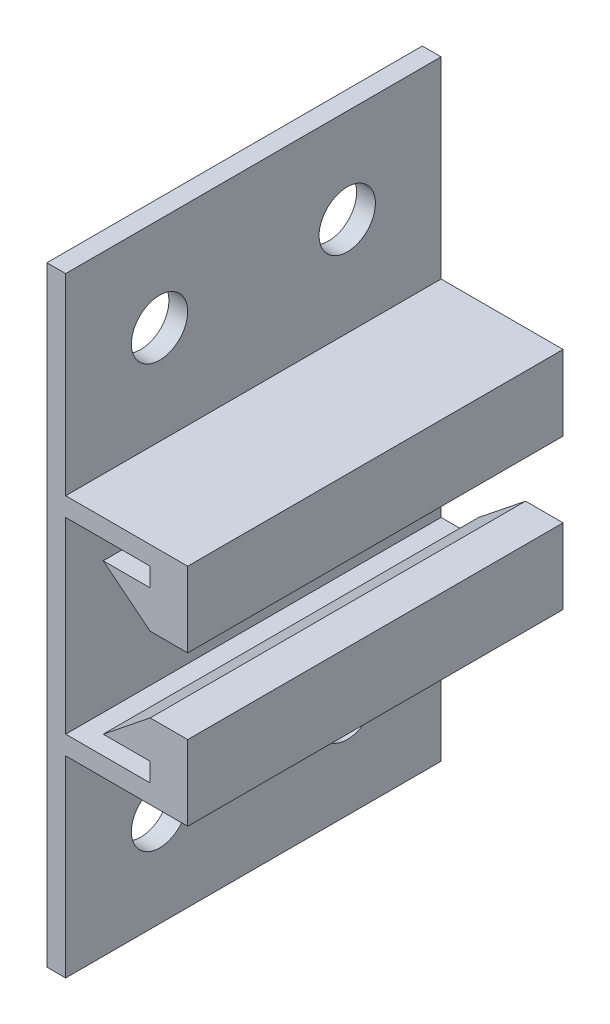
from build123d import *

# Parameters (mm, degrees)
BOSS_EXTRU_1_DEPTH         = 20
ESQUISSE2_R                = 1.5
ENL_V_MAT_EXTRU_1_DEPTH    = 2
R_P_TITION_LIN_AIRE1_COUNT = 2
R_P_TITION_LIN_AIRE1_PITCH = 10


with BuildPart() as part:
    # Esquisse1 → Boss.-Extru.1 (new body)
    with BuildSketch(Plane.XY):
        Polygon((1, 32.5), (1, 22.25), (7.5, 22.25), (7.5, 18.25), (5.5, 18.25), (3, 20.25), (5.5, 20.25), (5.5, 21.25), (1, 21.25), (1, 11.25), (5.5, 11.25), (5.5, 12.25), (3, 12.25), (5.5, 14.25), (7.5, 14.25), (7.5, 10.25), (1, 10.25), (1, 0), (0, 0), (0, 32.5), align=None)
    extrude(amount=BOSS_EXTRU_1_DEPTH)

    # Esquisse2 → Enlèv. mat.-Extru.1 (cut, through all)
    with BuildSketch(Plane(origin=(1, 0, 0), x_dir=(0, 0, -1), z_dir=(1, 0, 0))):
        with Locations((-15, 27.5)):
            Circle(ESQUISSE2_R)
        with Locations((-15, 5)):
            Circle(ESQUISSE2_R)
    enl_v_mat_extru_1 = extrude(amount=-ENL_V_MAT_EXTRU_1_DEPTH, mode=Mode.SUBTRACT)

    # Répétition linéaire1: Enlèv. mat.-Extru.1 ×2
    with Locations(*[(0, 0, -i * R_P_TITION_LIN_AIRE1_PITCH) for i in range(1, R_P_TITION_LIN_AIRE1_COUNT)]):
        add(enl_v_mat_extru_1, mode=Mode.SUBTRACT)


solid = part.part
